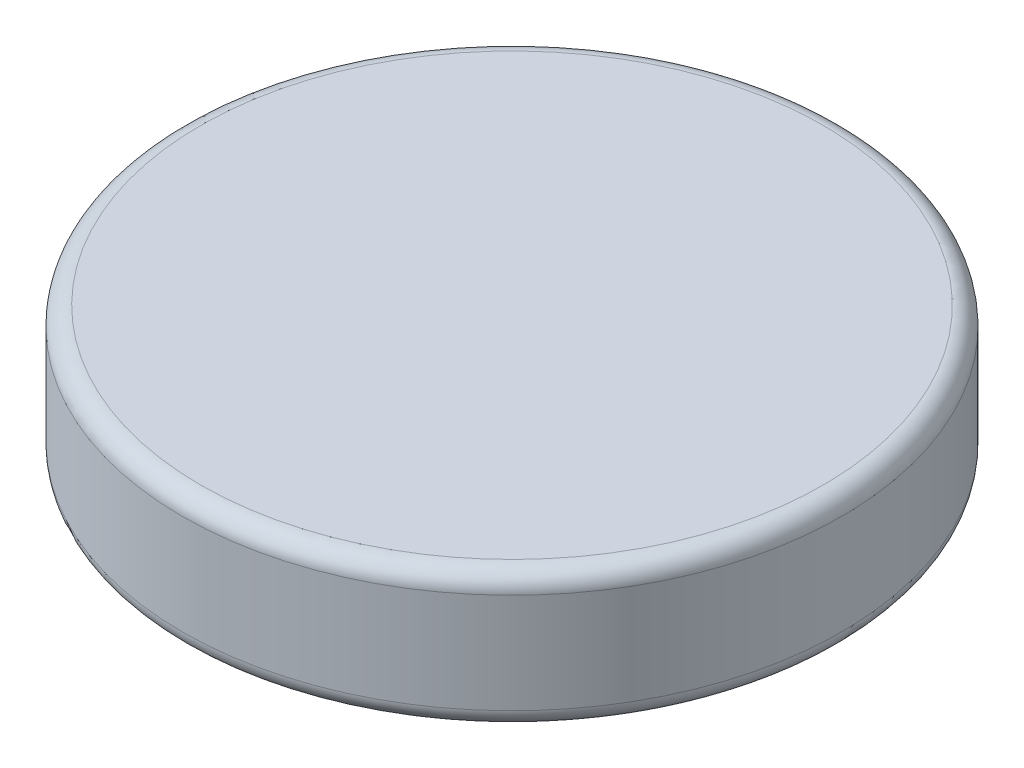
from build123d import *

# Parameters (mm, degrees)
SKETCH1_R           = 184.15
BOSS_EXTRUDE1_DEPTH = 76.2
FILLET1_R           = 10.16


with BuildPart() as part:
    # Sketch1 → Boss-Extrude1 (new body)
    with BuildSketch(Plane(origin=(0, 0, 0), x_dir=(1, 0, 0), z_dir=(0, 1, 0))):
        Circle(SKETCH1_R)
    extrude(amount=BOSS_EXTRUDE1_DEPTH)

    # Fillet1
    fillet1_edges = [part.edges().sort_by_distance(p)[0] for p in [
        (-184.15, 0, 0),
        (-184.15, 76.2, 0),
    ]]
    fillet(fillet1_edges, radius=FILLET1_R)


solid = part.part
